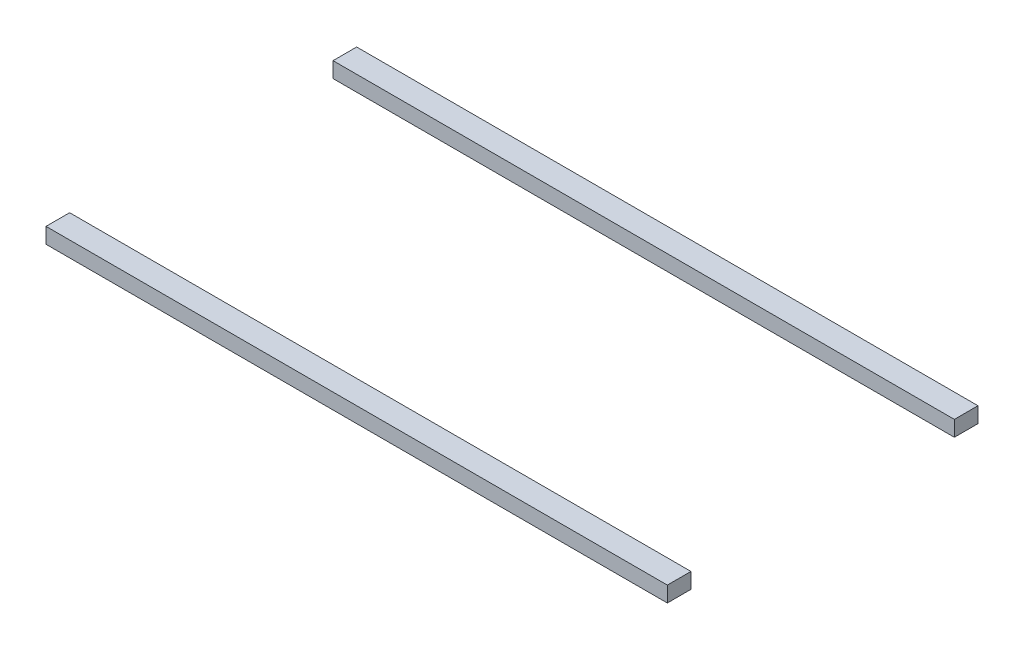
from build123d import *

# Parameters (mm, degrees)
SKETCH1_W             = 101.6
SKETCH1_H             = 3.866046113
BOSS_EXTRUDE2_DEPTH   = 2.54
BOSS_EXTRUDE2_2_DEPTH = 2.54


with BuildPart() as part:
    # Sketch1 → Boss-Extrude2 (new body)
    with BuildSketch(Plane(origin=(0, 0, 0), x_dir=(1, 0, 0), z_dir=(0, 1, 0))):
        with Locations((0, -23.466976944)):
            Rectangle(SKETCH1_W, SKETCH1_H)
    extrude(amount=BOSS_EXTRUDE2_DEPTH)


with BuildPart() as body_2:
    # Sketch1 → Boss-Extrude2 2 (new body)
    with BuildSketch(Plane(origin=(0, 0, 0), x_dir=(1, 0, 0), z_dir=(0, 1, 0))):
        with Locations((0, 23.466976944)):
            Rectangle(SKETCH1_W, SKETCH1_H)
    extrude(amount=BOSS_EXTRUDE2_2_DEPTH)


solid = Compound([part.part, body_2.part])
